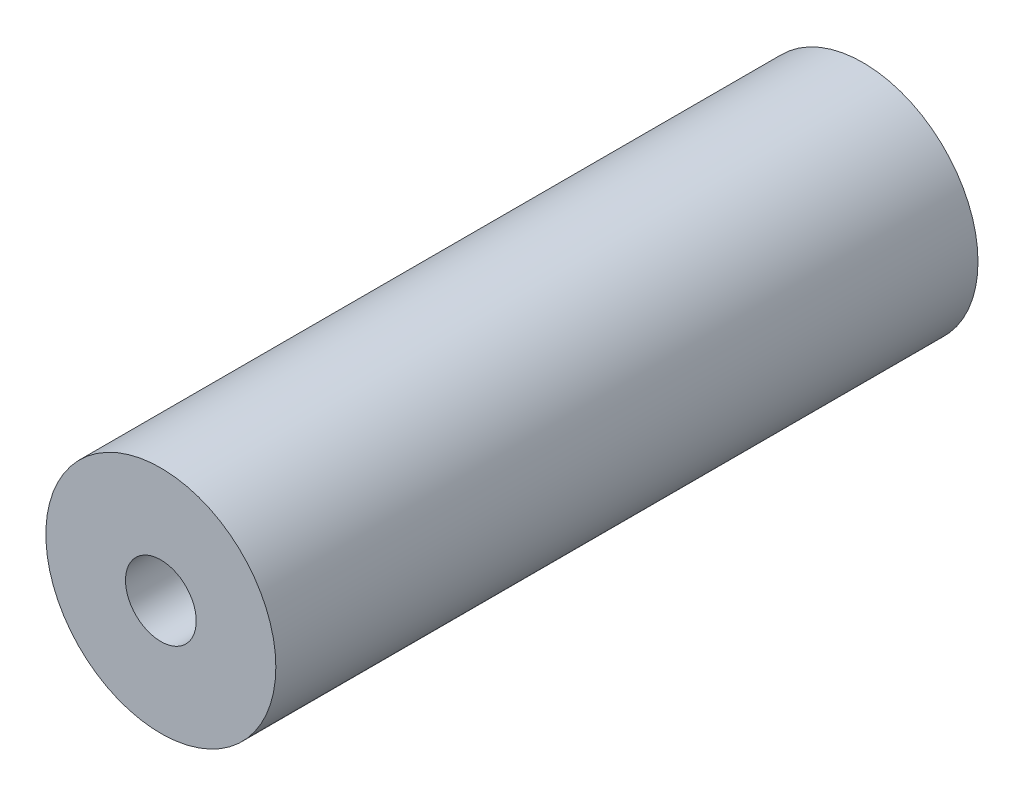
from build123d import *

# Parameters (mm, degrees)
SKETCH1_R           = 6.5
SKETCH1_R_2         = 2
BOSS_EXTRUDE1_DEPTH = 39.6875


with BuildPart() as part:
    # Sketch1 → Boss-Extrude1 (new body)
    with BuildSketch(Plane.XY):
        Circle(SKETCH1_R)
        Circle(SKETCH1_R_2, mode=Mode.SUBTRACT)
    extrude(amount=-BOSS_EXTRUDE1_DEPTH)


solid = part.part
